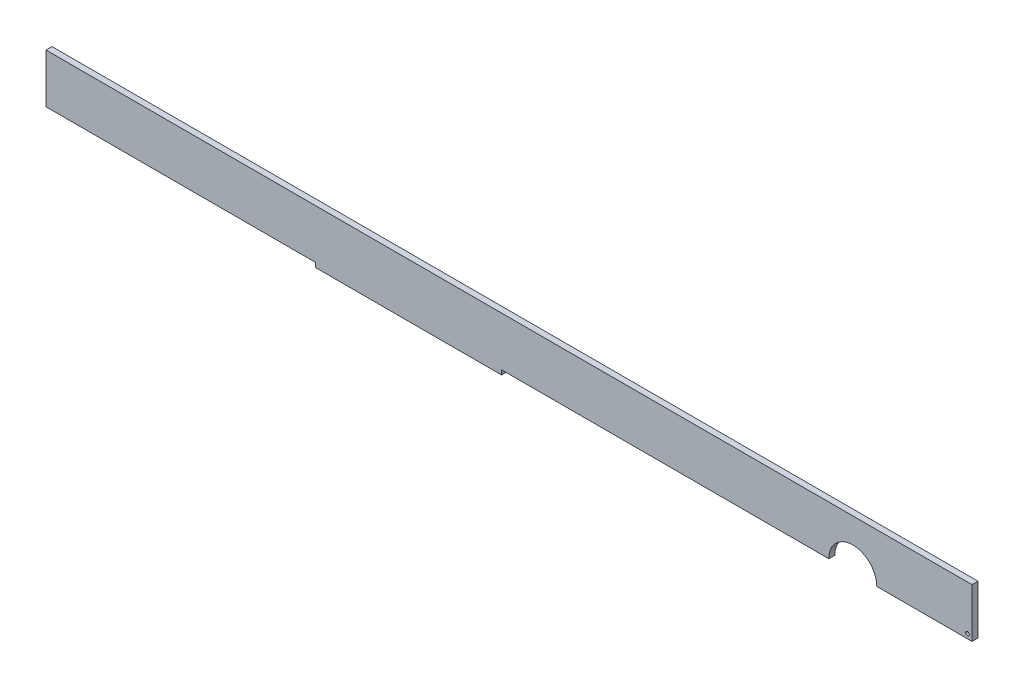
from build123d import *

# Parameters (mm, degrees)
DODANIE_WYCI_GNI_CIE1_DEPTH = 2
SZKIC2_R                    = 0.6
SZKIC2_R_2                  = 8
WYTNIJ_WYCI_GNI_CIE1_DEPTH  = 2


with BuildPart() as part:
    # Szkic1 → Dodanie-wyciągnięcie1 (new body)
    with BuildSketch(Plane.XY):
        Polygon((-111, 8.2), (188, 8.2), (188, -8.2), (31, -8.2), (31, -9.7), (-31, -9.7), (-31, -8.2), (-111, -8.2), (-121, -8.2), (-121, 8.2), align=None)
    extrude(amount=DODANIE_WYCI_GNI_CIE1_DEPTH)

    # Szkic2 → Wytnij-wyciągnięcie1 (cut)
    with BuildSketch(Plane(origin=(0, 0, 0), x_dir=(-1, 0, 0), z_dir=(0, 0, -1))):
        with Locations((-186.5, -6.7)):
            Circle(SZKIC2_R)
        with Locations((-186.5, 11.2)):
            Circle(SZKIC2_R)
        with Locations((186.5, 11.2)):
            Circle(SZKIC2_R)
        with Locations((186.5, -11.2)):
            Circle(SZKIC2_R)
        with Locations((-148.220730504, -8.2)):
            Circle(SZKIC2_R_2)
    extrude(amount=-WYTNIJ_WYCI_GNI_CIE1_DEPTH, mode=Mode.SUBTRACT)


solid = part.part
